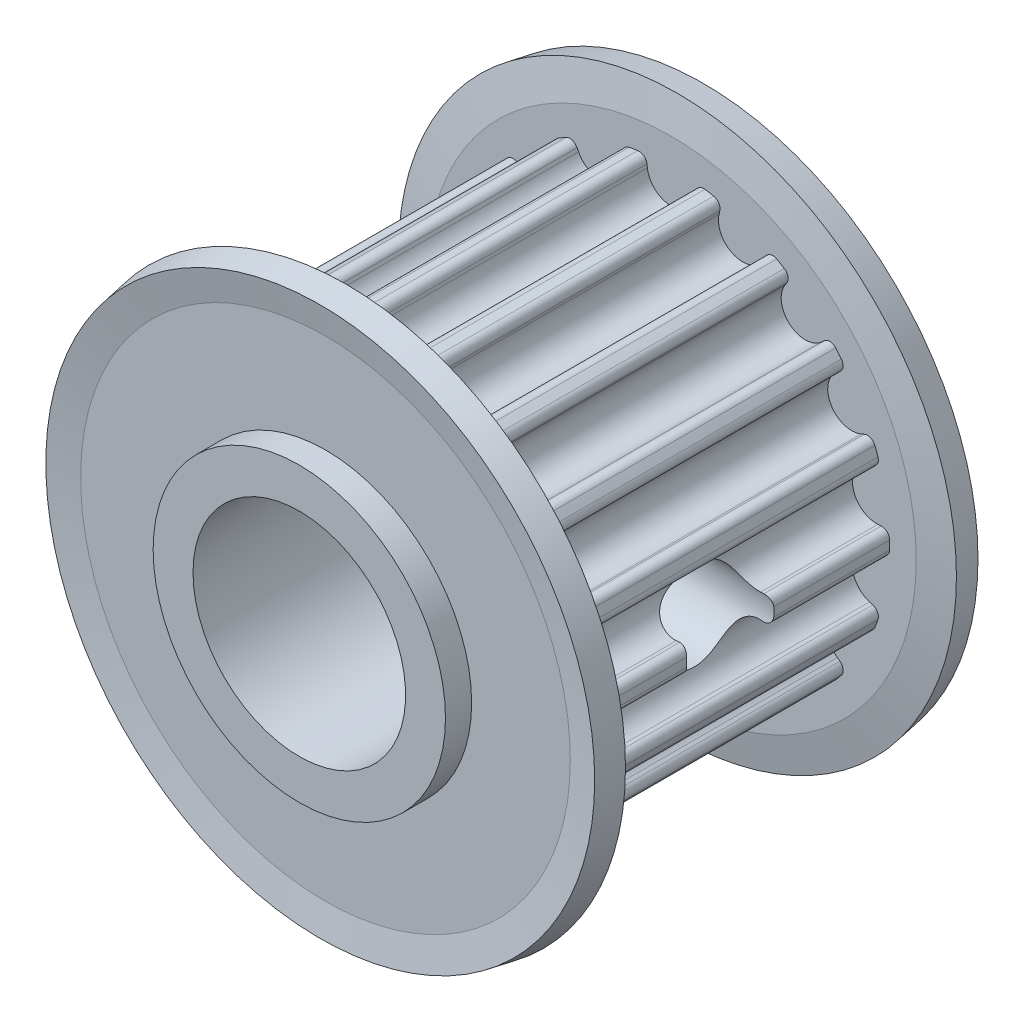
from build123d import *

# Parameters (mm, degrees)
TOOTH_EXTRUDE_START      = -6
TOOTH_EXTRUDE_DEPTH      = 12
TOOTH_PATTERN_COUNT      = 18
SKETCH_2_R               = 4
CUT_EXTRUDE_1_DEPTH      = 23
SKETCH_3_W               = 1.65
SKETCH_3_H               = 10.5
PATTERN_CIRCULAR_1_COUNT = 2
PATTERN_CIRCULAR_1_ANGLE = 90


with BuildPart() as part:
    # GearBelt-BaseSketch → HTD 5mm (revolve)
    with BuildSketch(Plane(origin=(0, 0, 0), x_dir=(0, 0, -1), z_dir=(1, 0, 0))):
        Polygon((-8, 0), (8, 0), (8, 5.5), (7.015426612, 5.5), (7.015426612, 9.213367074), (7.211675852, 10.326351822), (6.226868099, 10.5), (6, 9.213367074), (6, 8.213367074), (-6, 8.213367074), (-6, 9.213367074), (-6.226868099, 10.5), (-7.211675852, 10.326351822), (-7.015426612, 9.213367074), (-7.015426612, 5.5), (-8, 5.5), align=None)
    revolve(axis=Axis((0, 0, 10.8585), (0, 0, -1)))

    # Tooth-Sketch → Tooth-Extrude (cut)
    with BuildSketch(Plane.XY.offset(TOOTH_EXTRUDE_START)):
        with BuildLine():
            Line((-0.903216998, 7.732465971), (-0.918375292, 7.85592037))
            ThreePointArc((-0.918375292, 7.85592037), (-1.035260992, 8.05869844), (-1.262243626, 8.115795692))
            ThreePointArc((-1.262243626, 8.115795692), (0, 8.213367074), (1.262243626, 8.115795692))
            ThreePointArc((1.262243626, 8.115795692), (1.035260992, 8.05869844), (0.918375292, 7.85592037))
            Line((0.918375292, 7.85592037), (0.903216998, 7.732465971))
            ThreePointArc((0.903216998, 7.732465971), (0, 6.933367074), (-0.903216998, 7.732465971))
        make_face()
    tooth_extrude = extrude(amount=TOOTH_EXTRUDE_DEPTH, mode=Mode.SUBTRACT)

    # Tooth Pattern: Tooth-Extrude ×18 about axis
    tooth_pattern_axis = Axis((0, 0, 0), (0, 0, 1))
    for i in range(1, TOOTH_PATTERN_COUNT):
        add(tooth_extrude.rotate(tooth_pattern_axis, i * 360 / TOOTH_PATTERN_COUNT), mode=Mode.SUBTRACT)

    # Sketch 2 → Cut-Extrude 1 (cut)
    with BuildSketch(Plane(origin=(0, 0, -8), x_dir=(-1, 0, 0), z_dir=(0, 0, -1))):
        Circle(SKETCH_2_R)
    extrude(amount=-CUT_EXTRUDE_1_DEPTH, mode=Mode.SUBTRACT)

    # Sketch 3 → Hole Wizard M4 _1 (revolve, cut)
    with BuildSketch(Plane.ZX):
        with Locations((0.825, 5.25)):
            Rectangle(SKETCH_3_W, SKETCH_3_H)
    hole_wizard_m4_1 = revolve(axis=Axis((-6.35, 0, 0), (1, 0, 0)), mode=Mode.SUBTRACT)

    # Pattern Circular 1: Hole Wizard M4 _1 ×2 about axis
    pattern_circular_1_axis = Axis((0, 0, 15), (0, 0, -1))
    for i in range(1, PATTERN_CIRCULAR_1_COUNT):
        add(hole_wizard_m4_1.rotate(pattern_circular_1_axis, i * PATTERN_CIRCULAR_1_ANGLE / (PATTERN_CIRCULAR_1_COUNT - 1)), mode=Mode.SUBTRACT)


solid = part.part
